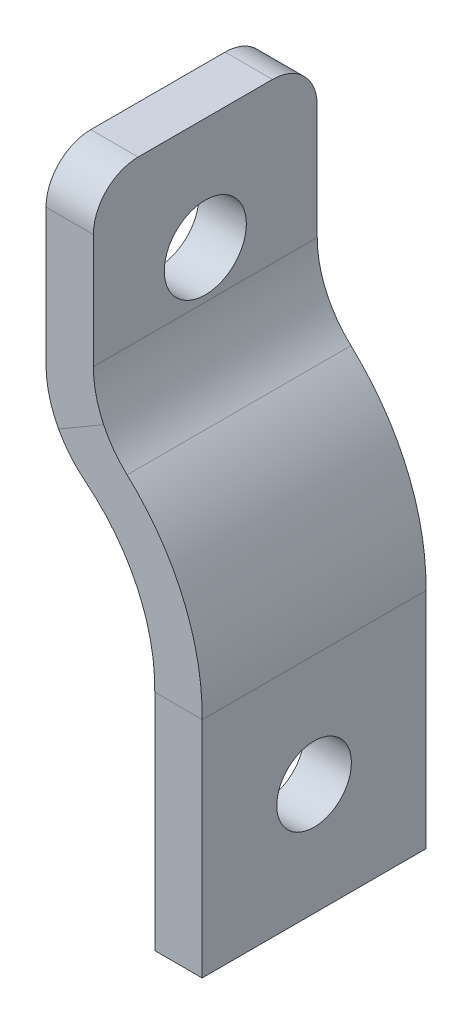
from build123d import *

# Parameters (mm, degrees)
FILLET1_R               = 7
M5_CLEARANCE_HOLE1_D    = 5.5
CUT_EXTRUDE1_DEPTH      = 37.52886072966826
CUT_EXTRUDE1_DEPTH_BACK = 37.52886072966826
SKETCH3_R               = 2.4999999999999996
FILLET2_R               = 3


with BuildPart() as part:
    # Sweep1: sweep along a path in Sketch1
    with BuildLine(Plane.XY) as sweep1_path:
        Line((-14.2875, 7.5), (-14.2875, -7.5))
        ThreePointArc((-14.2875, -7.5), (-8.903716825795872, -12.735560659438995), (-7.000000000000001, -20))
        Line((-7.000000000000001, -20), (-6.999999999999999, -35))
    # Sketch2 → Sweep1 (sweep)
    with BuildSketch(Plane(origin=(0, 0, 0), x_dir=(1, 0, 0), z_dir=(0, 1, 0))):
        Polygon((-12.699999999999996, -7.499999999999996), (-15.874999999999996, -7.499999999999996), (-15.874999999999996, 7.500000000000004), (-12.699999999999996, 7.500000000000005), align=None)
    sweep(path=sweep1_path.line, transition=Transition.RIGHT)

    # Fillet1
    fillet1_edges = [part.edges().sort_by_distance(p)[0] for p in [
        (-15.874999999999996, -8.441785890670294, -1.599e-14),
        (-12.699999999999996, -6.5917812273426035, -7.11e-15),
    ]]
    fillet(fillet1_edges, radius=FILLET1_R)

    # M5 Clearance Hole1 (through all)
    with Locations(Plane.ZY.offset(15.874999999999996)):
        with Locations((0, 0)):
            Hole(M5_CLEARANCE_HOLE1_D / 2)

    # Sketch3 → Cut-Extrude1 (cut, two sides: drawn at the far end of the back side and taken through both)
    with BuildSketch(Plane.ZY.offset(8.587500000000007).offset(-CUT_EXTRUDE1_DEPTH_BACK)):
        with Locations(Location((0, -27.500000000000004, 0), (0, 0, 270))):
            Circle(SKETCH3_R)
    extrude(amount=CUT_EXTRUDE1_DEPTH + CUT_EXTRUDE1_DEPTH_BACK, mode=Mode.SUBTRACT)

    # Fillet2
    fillet2_edges = [part.edges().sort_by_distance(p)[0] for p in [
        (-14.287499999999996, 7.5, 7.499999999999996),
        (-14.287499999999996, 7.5, -7.500000000000005),
    ]]
    fillet(fillet2_edges, radius=FILLET2_R)


solid = part.part
